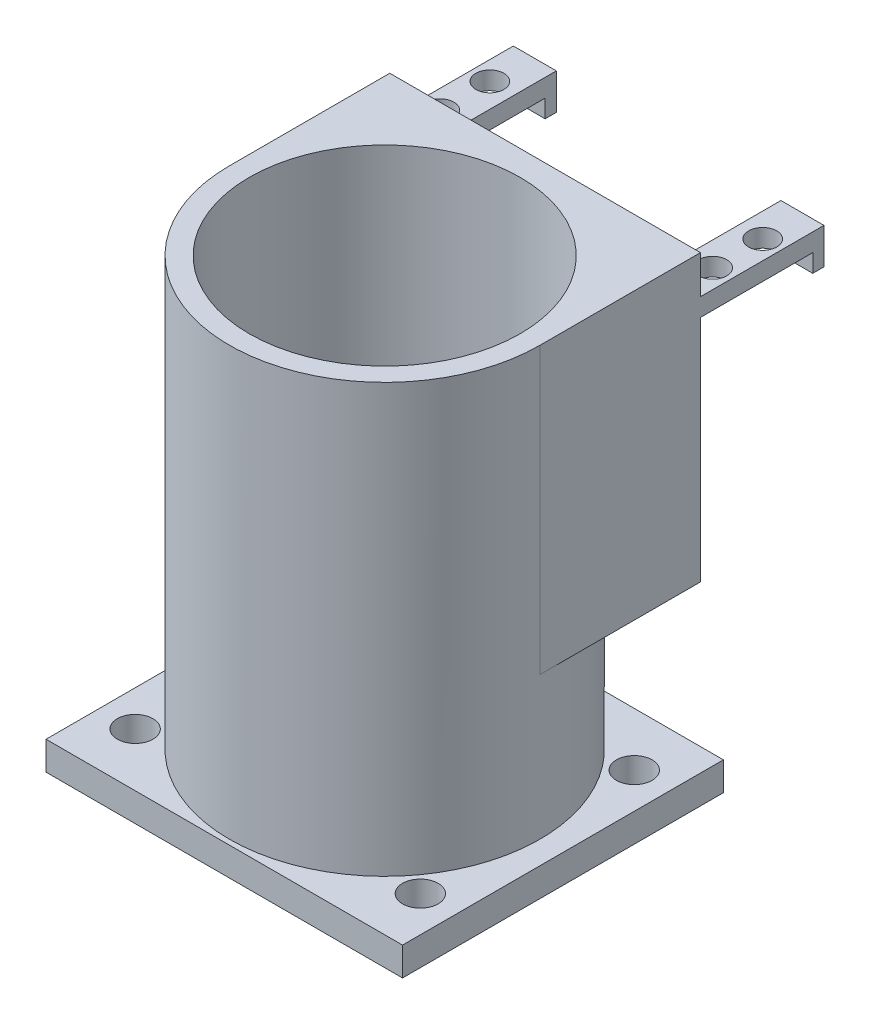
from build123d import *

# Parameters (mm, degrees)
SKETCH1_W           = 63.5
SKETCH1_H           = 57.15
SKETCH1_R           = 3.175
BOSS_EXTRUDE1_DEPTH = 5.08
SKETCH2_R           = 27.67
SKETCH2_R_2         = 24.13
BOSS_EXTRUDE2_DEPTH = 76.2
BOSS_EXTRUDE3_REACH = 59.15
SKETCH4_W           = 55.34
SKETCH4_H           = 50.8
SKETCH5_W           = 7.67
SKETCH5_H           = 3.2
BOSS_EXTRUDE4_DEPTH = 20
SKETCH6_R           = 2.5
CUT_EXTRUDE1_DEPTH  = 11
SKETCH7_W           = 7.67
SKETCH7_H           = 3.2
BOSS_EXTRUDE5_DEPTH = 2
SKETCH8_W           = 7.67
SKETCH8_H           = 2
BOSS_EXTRUDE6_DEPTH = 3.2


with BuildPart() as part:
    # Sketch1 → Boss-Extrude1 (new body)
    with BuildSketch(Plane(origin=(0, 0, 0), x_dir=(1, 0, 0), z_dir=(0, 1, 0))):
        with Locations((31.75, -28.575)):
            Rectangle(SKETCH1_W, SKETCH1_H)
        with Locations((6.35, -9.525)):
            Circle(SKETCH1_R, mode=Mode.SUBTRACT)
        with Locations((57.15, -9.525)):
            Circle(SKETCH1_R, mode=Mode.SUBTRACT)
        with Locations((57.15, -47.625)):
            Circle(SKETCH1_R, mode=Mode.SUBTRACT)
        with Locations((6.35, -47.625)):
            Circle(SKETCH1_R, mode=Mode.SUBTRACT)
    extrude(amount=BOSS_EXTRUDE1_DEPTH)

    # Sketch2 → Boss-Extrude2 (add)
    with BuildSketch(Plane(origin=(0, 5.08, 0), x_dir=(1, 0, 0), z_dir=(0, 1, 0))):
        with Locations((31.75, -28.575)):
            Circle(SKETCH2_R)
        with Locations((31.75, -28.575)):
            Circle(SKETCH2_R_2, mode=Mode.SUBTRACT)
    extrude(amount=BOSS_EXTRUDE2_DEPTH)

    # Sketch4 → Boss-Extrude3 (add, up to next)
    with BuildSketch(Plane(origin=(0, 0, 0), x_dir=(-1, 0, 0), z_dir=(0, 0, -1)), mode=Mode.PRIVATE) as boss_extrude3_sk1:
        with Locations((-31.75, 55.88)):
            Rectangle(SKETCH4_W, SKETCH4_H)
    boss_extrude3_tool1 = extrude(boss_extrude3_sk1.sketch, amount=-BOSS_EXTRUDE3_REACH, mode=Mode.PRIVATE) - part.part
    add(boss_extrude3_tool1.solids().sort_by_distance((31.75, 55.88, 0))[0])

    # Sketch5 → Boss-Extrude4 (add)
    with BuildSketch(Plane(origin=(0, 0, 0), x_dir=(-1, 0, 0), z_dir=(0, 0, -1))):
        with Locations((-7.915, 72.88)):
            Rectangle(SKETCH5_W, SKETCH5_H)
        with Locations((-55.585, 72.88)):
            Rectangle(SKETCH5_W, SKETCH5_H)
    extrude(amount=BOSS_EXTRUDE4_DEPTH)

    # Sketch6 → Cut-Extrude1 (cut, through all)
    with BuildSketch(Plane.XZ.offset(-71.28)):
        with Locations((7.45, -5.55)):
            Circle(SKETCH6_R)
        with Locations((56.05, -5.55)):
            Circle(SKETCH6_R)
        with Locations((56.05, -14.45)):
            Circle(SKETCH6_R)
        with Locations((7.45, -14.45)):
            Circle(SKETCH6_R)
    extrude(amount=-CUT_EXTRUDE1_DEPTH, mode=Mode.SUBTRACT)

    # Sketch7 → Boss-Extrude5 (add)
    with BuildSketch(Plane(origin=(0, 0, -20), x_dir=(-1, 0, 0), z_dir=(0, 0, -1))):
        with Locations((-55.585, 72.88)):
            Rectangle(SKETCH7_W, SKETCH7_H)
        with Locations((-7.915, 72.88)):
            Rectangle(SKETCH7_W, SKETCH7_H)
    extrude(amount=BOSS_EXTRUDE5_DEPTH)

    # Sketch8 → Boss-Extrude6 (add)
    with BuildSketch(Plane.XZ.offset(-71.28)):
        with Locations((7.915, -21)):
            Rectangle(SKETCH8_W, SKETCH8_H)
        with Locations((55.585, -21)):
            Rectangle(SKETCH8_W, SKETCH8_H)
    extrude(amount=BOSS_EXTRUDE6_DEPTH)


solid = part.part
